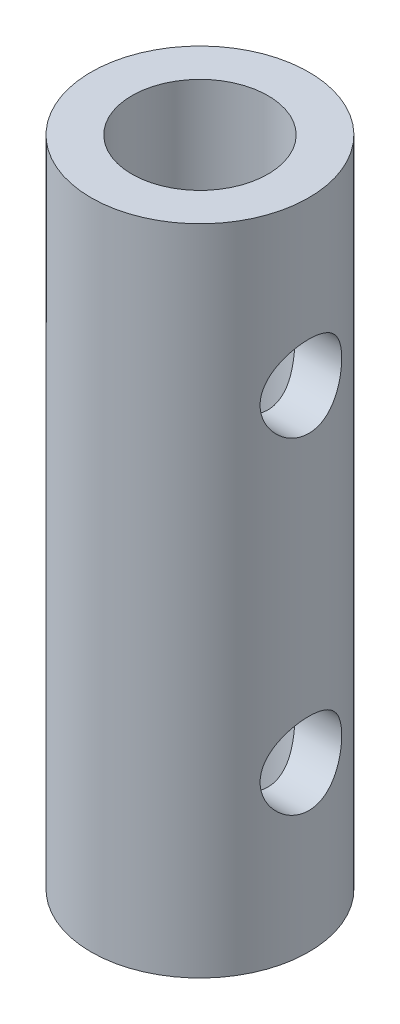
from build123d import *

# Parameters (mm, degrees)
SKETCH1_R               = 4
BOSS_EXTRUDE1_DEPTH     = 24
SKETCH2_R               = 2.5
CUT_EXTRUDE1_DEPTH      = 11
CUT_EXTRUDE2_START      = -11
SKETCH3_R               = 2.5
CUT_EXTRUDE2_DEPTH      = 11
CUT_EXTRUDE3_DEPTH      = 11
CUT_EXTRUDE3_DEPTH_BACK = 11
SKETCH4_R               = 1.5


with BuildPart() as part:
    # Sketch1 → Boss-Extrude1 (new body)
    with BuildSketch(Plane(origin=(0, 0, 0), x_dir=(1, 0, 0), z_dir=(0, 1, 0))):
        Circle(SKETCH1_R)
    extrude(amount=BOSS_EXTRUDE1_DEPTH)

    # Sketch2 → Cut-Extrude1 (cut)
    with BuildSketch(Plane(origin=(0, 24, 0), x_dir=(1, 0, 0), z_dir=(0, 1, 0))):
        Circle(SKETCH2_R)
    extrude(amount=-CUT_EXTRUDE1_DEPTH, mode=Mode.SUBTRACT)

    # Sketch3 → Cut-Extrude2 (cut)
    with BuildSketch(Plane.XZ.offset(CUT_EXTRUDE2_START)):
        Circle(SKETCH3_R)
    extrude(amount=CUT_EXTRUDE2_DEPTH, mode=Mode.SUBTRACT)

    # Sketch4 → Cut-Extrude3 (cut, two sides: drawn at the far end of the back side and taken through both)
    with BuildSketch(Plane(origin=(0, 0, 0), x_dir=(0, 0, -1), z_dir=(1, 0, 0)).offset(-CUT_EXTRUDE3_DEPTH_BACK)):
        with Locations((0, 18)):
            Circle(SKETCH4_R)
        with Locations((0, 6)):
            Circle(SKETCH4_R)
    extrude(amount=CUT_EXTRUDE3_DEPTH + CUT_EXTRUDE3_DEPTH_BACK, mode=Mode.SUBTRACT)


solid = part.part
